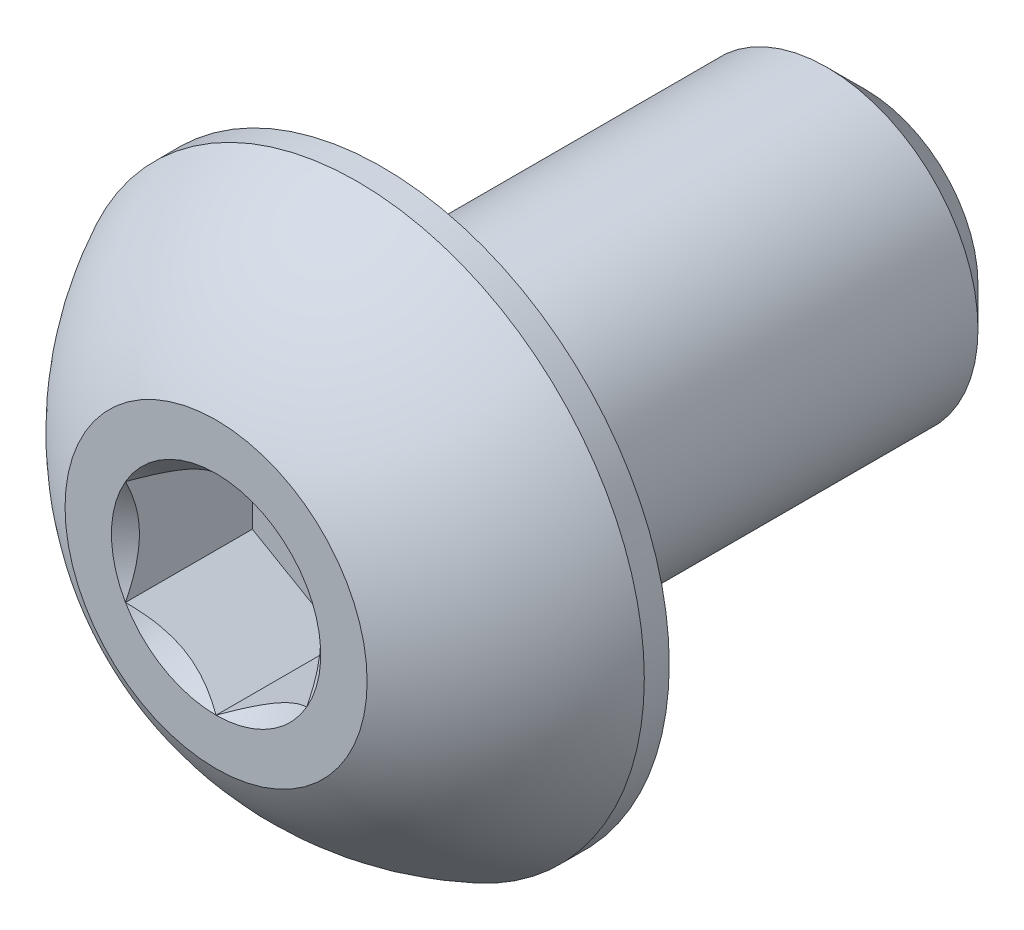
from build123d import *

# Parameters (mm, degrees)
CUT_EXTRUDE1_DEPTH = 2.1


with BuildPart() as part:
    # Sketch2 → Revolve1 (revolve)
    with BuildSketch(Plane(origin=(0, 0, 0), x_dir=(0, 0, -1), z_dir=(1, 0, 0)), mode=Mode.PRIVATE) as revolve1_sk:
        with BuildLine():
            Line((-5.375, 0), (5.375, 0))
            Line((5.375, 0), (5.375, 1.86))
            Line((5.375, 1.86), (4.735, 2.5))
            Line((4.735, 2.5), (-2.625, 2.5))
            Line((-2.625, 2.5), (-2.625, 4.75))
            Line((-2.625, 4.75), (-3.0375, 4.75))
            ThreePointArc((-3.0375, 4.75), (-4.383124817, 3.808753282), (-5.375, 2.5))
            Line((-5.375, 2.5), (-5.375, 0))
        make_face()
    revolve(revolve1_sk.sketch.rotate(Axis((0, 0, 5.375), (0, 0, -1)), 90), axis=Axis((0, 0, 5.375), (0, 0, -1)))

    # Sketch3 → Cut-Extrude1 (cut)
    with BuildSketch(Plane.XY.offset(5.375)):
        Polygon((0, 1.732050808), (-1.5, 0.866025404), (-1.5, -0.866025404), (0, -1.732050808), (1.5, -0.866025404), (1.5, 0.866025404), align=None)
    extrude(amount=-CUT_EXTRUDE1_DEPTH, mode=Mode.SUBTRACT)

    # Cut-Extrude2 cone 1 section (through the dimple's axis) → Cut-Extrude2 (revolve, cut)
    with BuildSketch(Plane(origin=(0, 0, 5.375), x_dir=(0, -1, 0), z_dir=(1, 0, 0))):
        Polygon((0, 0), (1.732050808, 0), (0, 1.732050808), align=None)
    revolve(axis=Axis((0, 0, 5.375), (0, 0, -1)), mode=Mode.SUBTRACT)


solid = part.part
